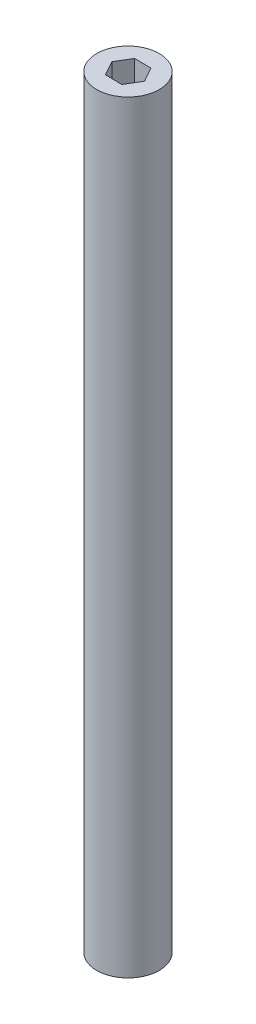
from build123d import *

# Parameters (mm, degrees)
SKETCH1_R           = 12.698048489
BOSS_EXTRUDE1_DEPTH = 309.88


with BuildPart() as part:
    # Sketch1 → Boss-Extrude1 (new body)
    with BuildSketch(Plane(origin=(0, 0, 0), x_dir=(1, 0, 0), z_dir=(0, 1, 0))):
        Circle(SKETCH1_R)
        Polygon((3.296602923, -5.830579037), (6.765660814, -0.044613993), (3.489397046, 5.852660789), (-3.255924613, 5.963970528), (-6.724982504, 0.178005484), (-3.448718736, -5.719269298), align=None, mode=Mode.SUBTRACT)
    extrude(amount=BOSS_EXTRUDE1_DEPTH)


solid = part.part
